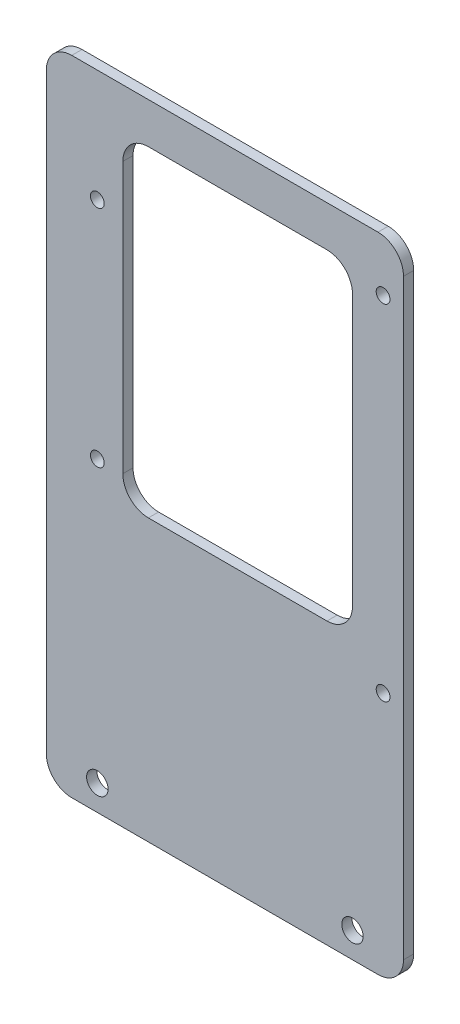
from build123d import *

# Parameters (mm, degrees)
SKETCH_1_W          = 70
SKETCH_1_H          = 126
EXTRUDE_1_DEPTH     = 2
FILLET_1_R          = 5
SKETCH_2_R          = 2.1
SKETCH_2_R_2        = 1.35
CUT_EXTRUDE_1_DEPTH = 3
SKETCH_3_W          = 45
SKETCH_3_H          = 63
CUT_EXTRUDE_2_DEPTH = 10
FILLET_2_R          = 5


with BuildPart() as part:
    # 草图1 → 凸台-拉伸1 (new body)
    with BuildSketch(Plane.XY):
        Rectangle(SKETCH_1_W, SKETCH_1_H)
    extrude(amount=EXTRUDE_1_DEPTH)

    # 圆角1
    fillet_1_edges = [part.edges().sort_by_distance(p)[0] for p in [
        (35, -63, 1),
        (-35, -63, 1),
        (-35, 63, 1),
        (35, 63, 1),
    ]]
    fillet(fillet_1_edges, radius=FILLET_1_R)

    # 草图2 → 切除-拉伸1 (cut, through all)
    with BuildSketch(Plane.XY.offset(2)):
        with Locations((-25, -58)):
            Circle(SKETCH_2_R)
        with Locations((25, -58)):
            Circle(SKETCH_2_R)
        with Locations((-25, -3)):
            Circle(SKETCH_2_R_2)
        with Locations((-25, 41)):
            Circle(SKETCH_2_R_2)
        with Locations((31, 52.75)):
            Circle(SKETCH_2_R_2)
        with Locations((31, -14.75)):
            Circle(SKETCH_2_R_2)
    extrude(amount=-CUT_EXTRUDE_1_DEPTH, mode=Mode.SUBTRACT)

    # 草图3 → 切除-拉伸2 (cut)
    with BuildSketch(Plane.XY.offset(2)):
        with Locations((2.5, 23.5)):
            Rectangle(SKETCH_3_W, SKETCH_3_H)
    extrude(amount=-CUT_EXTRUDE_2_DEPTH, mode=Mode.SUBTRACT)

    # 圆角2
    fillet_2_edges = [part.edges().sort_by_distance(p)[0] for p in [
        (25, 55, 1),
        (25, -8, 1),
        (-20, -8, 1),
        (-20, 55, 1),
    ]]
    fillet(fillet_2_edges, radius=FILLET_2_R)


solid = part.part
